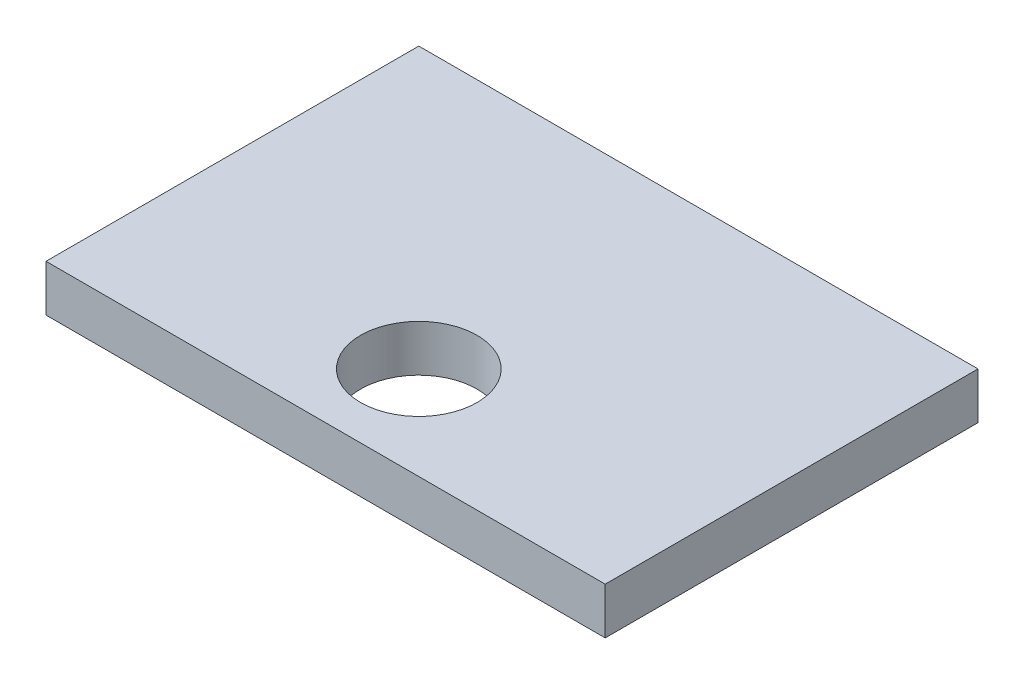
from build123d import *

# Parameters (mm, degrees)
SKETCH2_W           = 120
SKETCH2_H           = 80
BOSS_EXTRUDE1_DEPTH = 10
SKETCH3_R           = 12.5
CUT_EXTRUDE1_DEPTH  = 10


with BuildPart() as part:
    # Sketch2 → Boss-Extrude1 (new body)
    with BuildSketch(Plane(origin=(0, 0, 0), x_dir=(1, 0, 0), z_dir=(0, 1, 0))):
        with Locations((60, 40)):
            Rectangle(SKETCH2_W, SKETCH2_H)
    extrude(amount=BOSS_EXTRUDE1_DEPTH)

    # Sketch3 → Cut-Extrude1 (cut)
    with BuildSketch(Plane(origin=(0, 10, 0), x_dir=(1, 0, 0), z_dir=(0, 1, 0))):
        with Locations((60, 20)):
            Circle(SKETCH3_R)
    extrude(amount=-CUT_EXTRUDE1_DEPTH, mode=Mode.SUBTRACT)


solid = part.part
